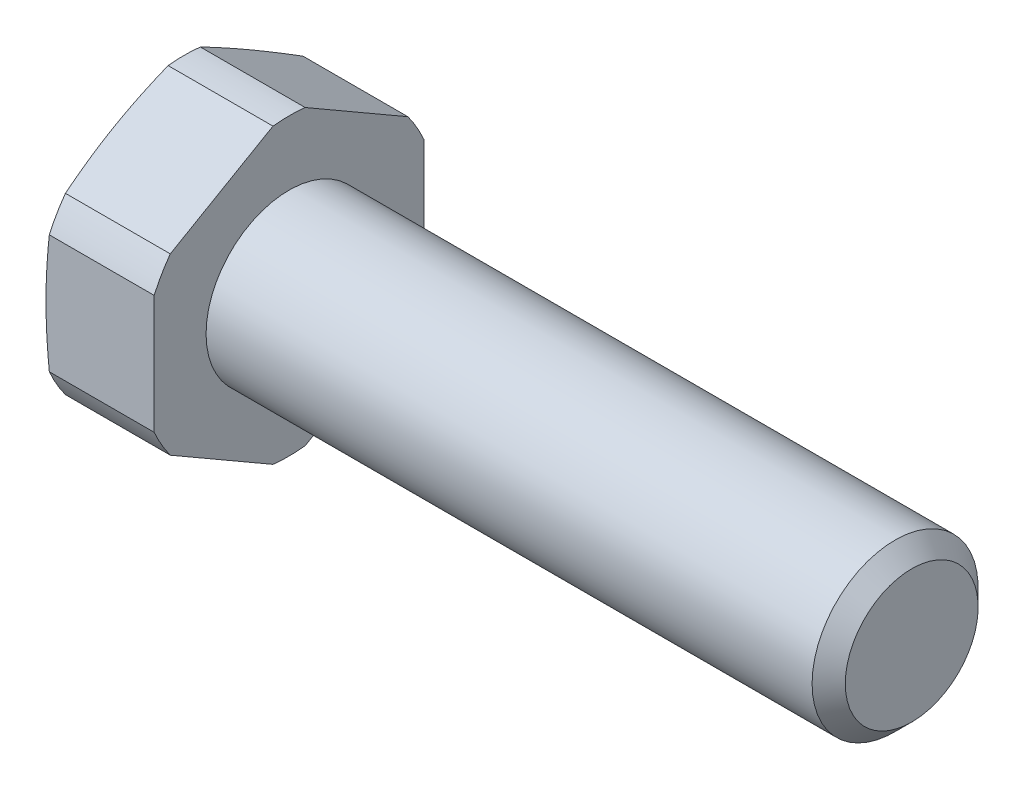
from build123d import *

# Parameters (mm, degrees)
SKETCH_2_OUTSIDE_W  = 24.322
SKETCH_2_OUTSIDE_H  = 24.322
CUT_EXTRUDE_1_DEPTH = 35.3


with BuildPart() as part:
    # Эскиз1 → Повернуть1 (revolve)
    with BuildSketch(Plane.XY):
        Polygon((-5.3, 0), (-5.3, 6.175), (-5.052146997, 7.1), (0, 7.1), (0, 4), (29.2, 4), (30, 3.2), (30, 0), align=None)
    revolve(axis=Axis((-1000, 0, 0), (1, 0, 0)))

    # Эскиз2 outside → Вырез-Вытянуть1 (cut)
    with BuildSketch(Plane.ZY.offset(5.3)):
        Rectangle(SKETCH_2_OUTSIDE_W, SKETCH_2_OUTSIDE_H)
        Polygon((0, 7.505553499), (-6.5, 3.75277675), (-6.5, -3.75277675), (0, -7.505553499), (6.5, -3.75277675), (6.5, 3.75277675), align=None, mode=Mode.SUBTRACT)
    extrude(amount=-CUT_EXTRUDE_1_DEPTH, mode=Mode.SUBTRACT)


solid = part.part
